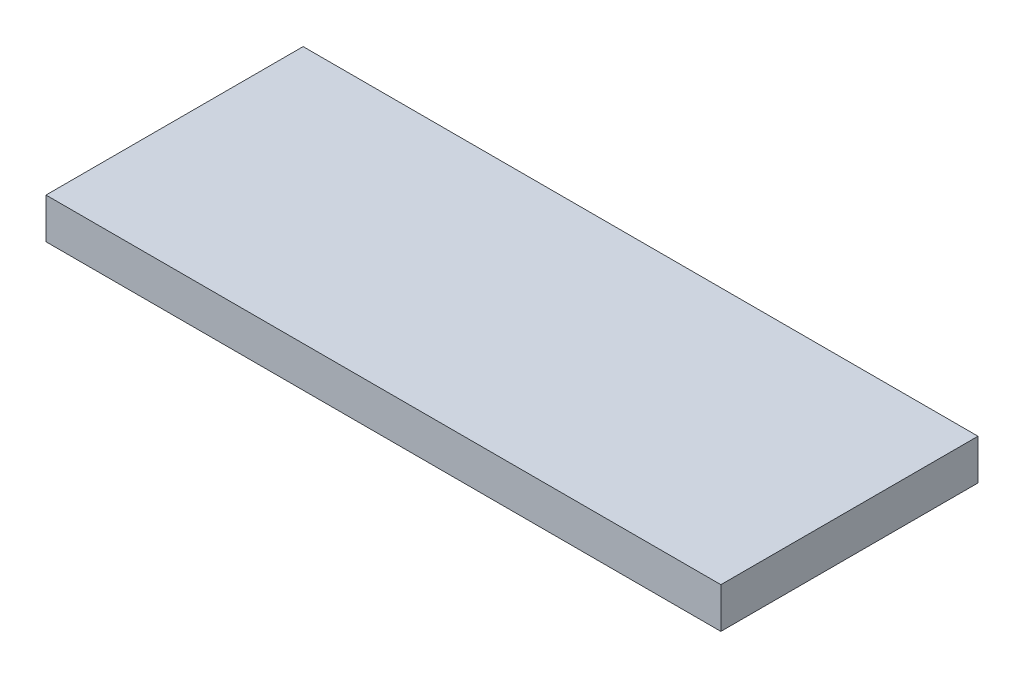
from build123d import *

# Parameters (mm, degrees)
SKETCH1_W           = 50
SKETCH1_H           = 19.05
BOSS_EXTRUDE1_DEPTH = 3


with BuildPart() as part:
    # Sketch1 → Boss-Extrude1 (new body)
    with BuildSketch(Plane(origin=(0, 0, 0), x_dir=(1, 0, 0), z_dir=(0, 1, 0))):
        Rectangle(SKETCH1_W, SKETCH1_H)
    extrude(amount=BOSS_EXTRUDE1_DEPTH)


solid = part.part
